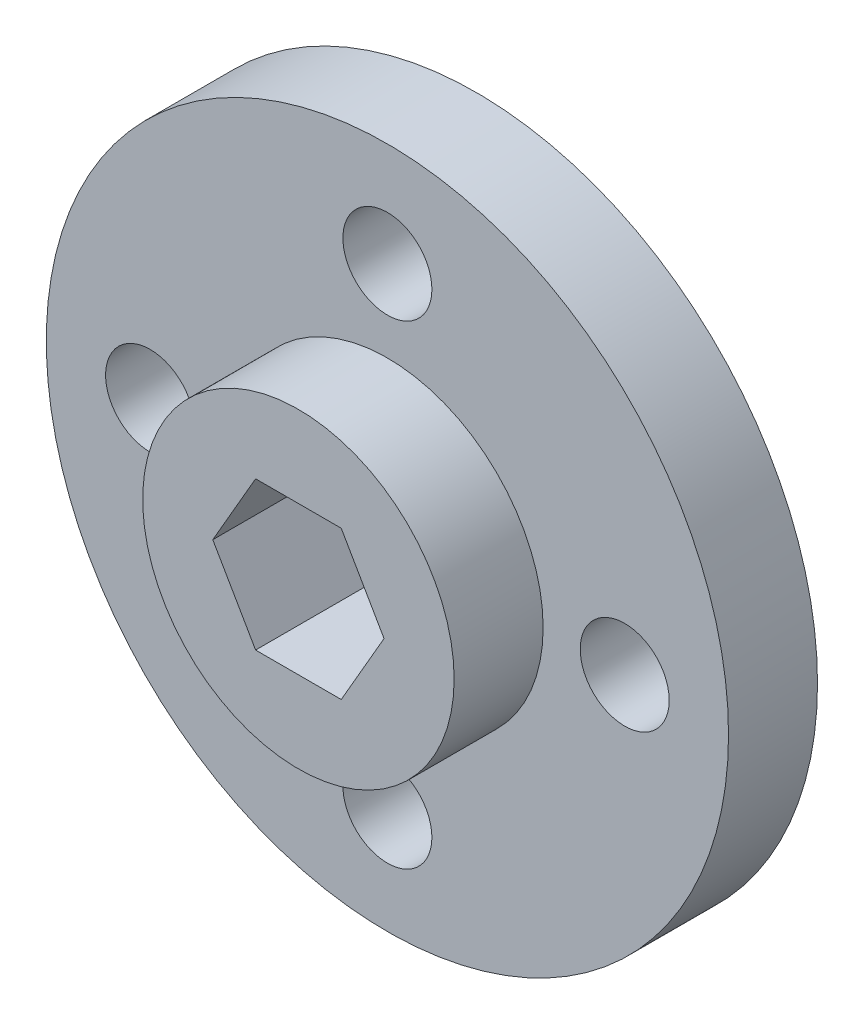
from build123d import *

# Parameters (mm, degrees)
SKETCH_1_R          = 11.5
SKETCH_1_R_2        = 1.5
EXTRUDE_1_DEPTH     = 3
SKETCH_2_R          = 5.25
EXTRUDE_2_DEPTH     = 3
CUT_EXTRUDE_1_DEPTH = 4.5
CUT_EXTRUDE_2_REACH = 3.5
SKETCH_4_R          = 1.65


with BuildPart() as part:
    # 草圖1 → 填料-伸長1 (new body)
    with BuildSketch(Plane.XY):
        Circle(SKETCH_1_R)
        with Locations((0, 8)):
            Circle(SKETCH_1_R_2, mode=Mode.SUBTRACT)
        with Locations((8, 0)):
            Circle(SKETCH_1_R_2, mode=Mode.SUBTRACT)
        with Locations((0, -8)):
            Circle(SKETCH_1_R_2, mode=Mode.SUBTRACT)
        with Locations((-8, 0)):
            Circle(SKETCH_1_R_2, mode=Mode.SUBTRACT)
    extrude(amount=EXTRUDE_1_DEPTH)

    # 草圖2 → 填料-伸長2 (add)
    with BuildSketch(Plane.XY.offset(3)):
        Circle(SKETCH_2_R)
    extrude(amount=EXTRUDE_2_DEPTH)

    # 草圖3 → 除料-伸長1 (cut)
    with BuildSketch(Plane.XY.offset(6)):
        Polygon((2.886751346, 0), (1.443375673, 2.5), (-1.443375673, 2.5), (-2.886751346, 0), (-1.443375673, -2.5), (1.443375673, -2.5), align=None)
    extrude(amount=-CUT_EXTRUDE_1_DEPTH, mode=Mode.SUBTRACT)

    # 草圖4 → 除料-伸長2 (cut, up to next)
    with BuildSketch(Plane.XY.offset(1.5), mode=Mode.PRIVATE) as cut_extrude_2_sk1:
        Circle(SKETCH_4_R)
    cut_extrude_2_tool1 = extrude(cut_extrude_2_sk1.sketch, amount=-CUT_EXTRUDE_2_REACH, mode=Mode.PRIVATE) & part.part
    add(cut_extrude_2_tool1.solids().sort_by_distance((0, 0, 1.5))[0], mode=Mode.SUBTRACT)


solid = part.part
